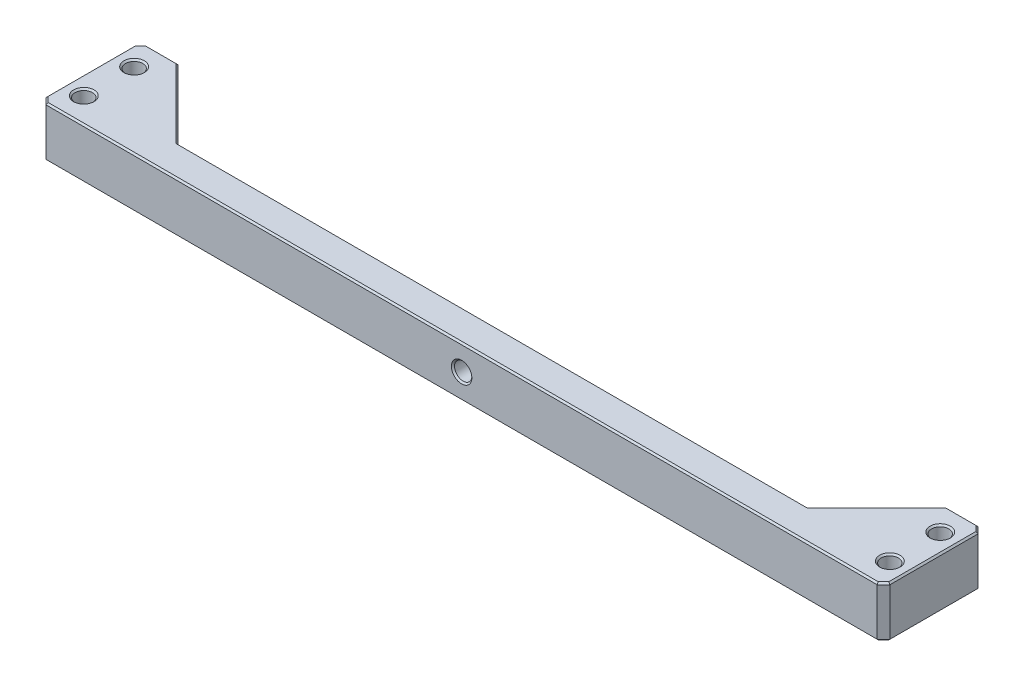
from build123d import *

# Parameters (mm, degrees)
SKETCH1_R               = 2.1828125
BOSS_EXTRUDE1_DEPTH     = 12.7
CHAMFER1_SIZE           = 1.5875
SKETCH2_R               = 2.1828125
CUT_EXTRUDE1_DEPTH      = 1
CUT_EXTRUDE1_DEPTH_BACK = 26.4
CHAMFER2_SIZE           = 0.396875


with BuildPart() as part:
    # Sketch1 → Boss-Extrude1 (new body)
    with BuildSketch(Plane(origin=(0, 0, 0), x_dir=(1, 0, 0), z_dir=(0, 1, 0))):
        Polygon((-106.3625, -6.35), (106.3625, -6.35), (106.3625, 19.05), (96.8375, 19.05), (79.375, 1.5875), (-79.375, 1.5875), (-96.8375, 19.05), (-106.3625, 19.05), align=None)
        with Locations((-101.6, 0)):
            Circle(SKETCH1_R, mode=Mode.SUBTRACT)
        with Locations((-101.6, 12.7)):
            Circle(SKETCH1_R, mode=Mode.SUBTRACT)
        with Locations((101.6, 0)):
            Circle(SKETCH1_R, mode=Mode.SUBTRACT)
        with Locations((101.6, 12.7)):
            Circle(SKETCH1_R, mode=Mode.SUBTRACT)
    extrude(amount=BOSS_EXTRUDE1_DEPTH)

    # Chamfer1
    chamfer1_edges = [part.edges().sort_by_distance(p)[0] for p in [
        (106.3625, 6.35, -19.05),
        (106.3625, 6.35, 6.35),
        (-106.3625, 6.35, 6.35),
        (-106.3625, 6.35, -19.05),
    ]]
    chamfer(chamfer1_edges, length=CHAMFER1_SIZE)

    # Sketch2 → Cut-Extrude1 (cut, two sides)
    with BuildSketch(Plane.XY.offset(6.35)) as cut_extrude1_sk:
        with Locations((0, 6.35)):
            Circle(SKETCH2_R)
    extrude(amount=CUT_EXTRUDE1_DEPTH, mode=Mode.SUBTRACT)
    extrude(cut_extrude1_sk.sketch, amount=-CUT_EXTRUDE1_DEPTH_BACK, mode=Mode.SUBTRACT)

    # Chamfer2
    chamfer2_edges = [part.edges().sort_by_distance(p)[0] for p in [
        (-88.10625, 0, -10.31875),
        (0, 0, -1.5875),
        (88.10625, 0, -10.31875),
        (0, 12.7, -1.5875),
        (-88.10625, 12.7, -10.31875),
        (-100.80625, 12.7, -19.05),
        (-103.7828125, 0, 0),
        (-103.7828125, 12.7, 0),
        (-103.7828125, 0, -12.7),
        (-103.7828125, 12.7, -12.7),
        (99.4171875, 0, 0),
        (99.4171875, 12.7, 0),
        (99.4171875, 0, -12.7),
        (99.4171875, 12.7, -12.7),
        (100.80625, 0, -19.05),
        (100.80625, 12.7, -19.05),
        (106.3625, 0, -6.35),
        (0, 0, 6.35),
        (-106.3625, 0, -6.35),
        (-105.56875, 0, 5.55625),
        (-105.56875, 0, -18.25625),
        (105.56875, 0, 5.55625),
        (105.56875, 0, -18.25625),
        (106.3625, 12.7, -6.35),
        (-106.3625, 12.7, -6.35),
        (0, 12.7, 6.35),
        (-105.56875, 12.7, 5.55625),
        (-105.56875, 12.7, -18.25625),
        (105.56875, 12.7, 5.55625),
        (105.56875, 12.7, -18.25625),
        (-2.1828125, 6.35, 6.35),
        (-2.1828125, 6.35, -1.5875),
        (88.10625, 12.7, -10.31875),
        (-100.80625, 0, -19.05),
    ]]
    chamfer(chamfer2_edges, length=CHAMFER2_SIZE)


solid = part.part
